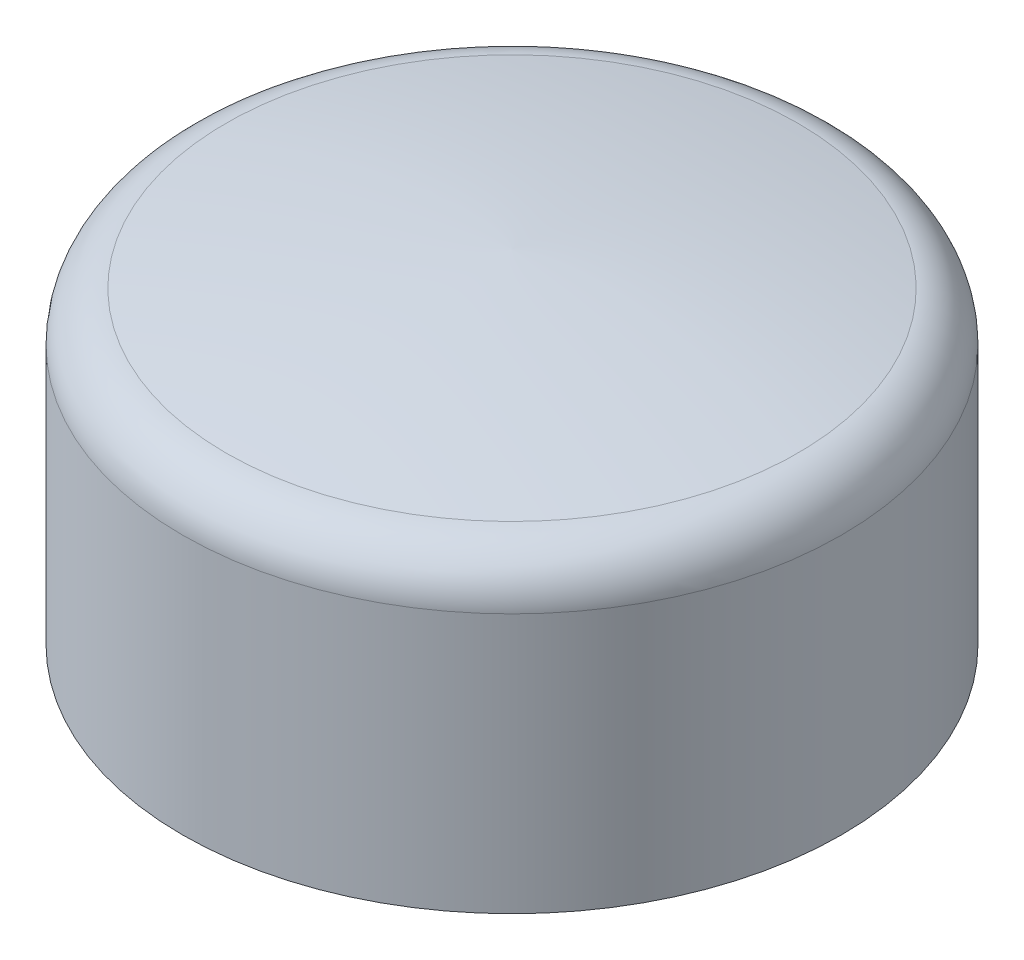
from build123d import *


with BuildPart() as part:
    # Sketch1 → Revolve1 (revolve)
    with BuildSketch(Plane.XY, mode=Mode.PRIVATE) as revolve1_sk:
        with BuildLine():
            Line((-33.3, -2.774413239), (-33.3, 23.466766742))
            ThreePointArc((-33.3, 23.466766742), (-32.036457548, 26.789248494), (-28.884446003, 28.43249155))
            ThreePointArc((-28.884446003, 28.43249155), (-14.508993899, 30.699600166), (0, 31.832075632))
            Line((0, 31.832075632), (0, 23.525586761))
            ThreePointArc((0, 23.525586761), (-12.549783711, 22.570084178), (-25, 20.725586761))
            Line((-25, 20.725586761), (-25, -2.774413239))
            Line((-25, -2.774413239), (-33.3, -2.774413239))
        make_face()
    revolve(revolve1_sk.sketch.rotate(Axis((0, 0, 0), (0, 1, 0)), 270), axis=Axis((0, 0, 0), (0, 1, 0)))


solid = part.part
